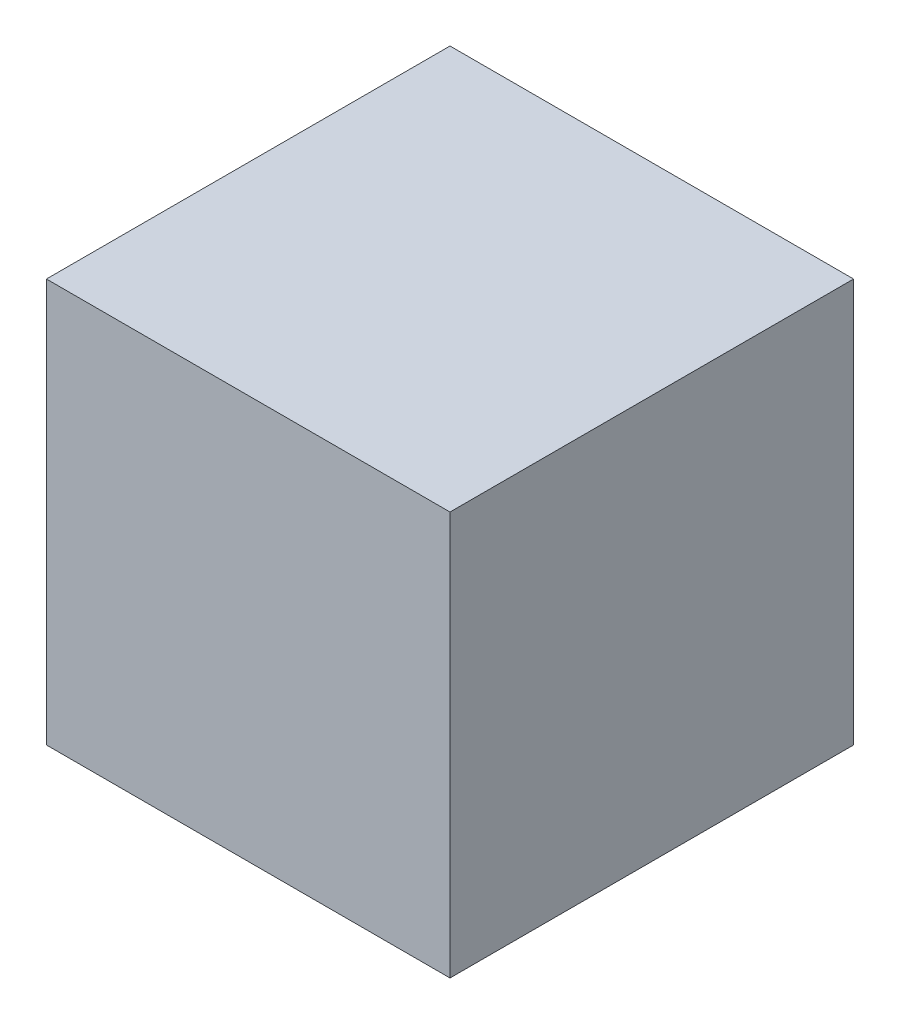
from build123d import *

# Parameters (mm, degrees)
SKETCH1_W           = 10
SKETCH1_H           = 10
BOSS_EXTRUDE1_DEPTH = 10


with BuildPart() as part:
    # Sketch1 → Boss-Extrude1 (new body)
    with BuildSketch(Plane.XY):
        with Locations((-5, 5)):
            Rectangle(SKETCH1_W, SKETCH1_H)
    extrude(amount=BOSS_EXTRUDE1_DEPTH)


solid = part.part
